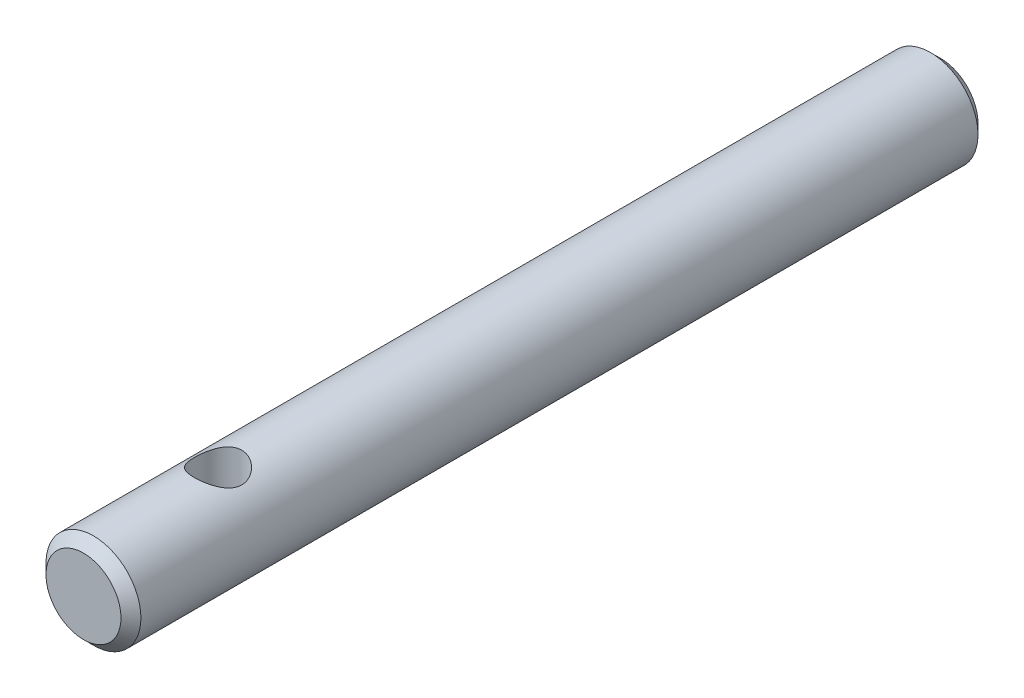
from build123d import *

# Parameters (mm, degrees)
SKETCH1_R               = 2.38125
BOSS_EXTRUDE1_DEPTH     = 43
SKETCH2_R               = 1.190625
CUT_EXTRUDE1_DEPTH      = 3.38125
CUT_EXTRUDE1_DEPTH_BACK = 3.38125
CHAMFER1_SIZE           = 0.5


with BuildPart() as part:
    # Sketch1 → Boss-Extrude1 (new body)
    with BuildSketch(Plane.XY):
        Circle(SKETCH1_R)
    extrude(amount=-BOSS_EXTRUDE1_DEPTH)

    # Sketch2 → Cut-Extrude1 (cut, two sides)
    with BuildSketch(Plane(origin=(0, 0, 0), x_dir=(1, 0, 0), z_dir=(0, 1, 0))) as cut_extrude1_sk:
        with Locations((0, 6.75)):
            Circle(SKETCH2_R)
    extrude(amount=CUT_EXTRUDE1_DEPTH, mode=Mode.SUBTRACT)
    extrude(cut_extrude1_sk.sketch, amount=-CUT_EXTRUDE1_DEPTH_BACK, mode=Mode.SUBTRACT)

    # Chamfer1
    chamfer1_edges = [part.edges().sort_by_distance(p)[0] for p in [
        (-2.38125, 0, 0),
        (-2.38125, 0, -43),
    ]]
    chamfer(chamfer1_edges, length=CHAMFER1_SIZE)


solid = part.part
